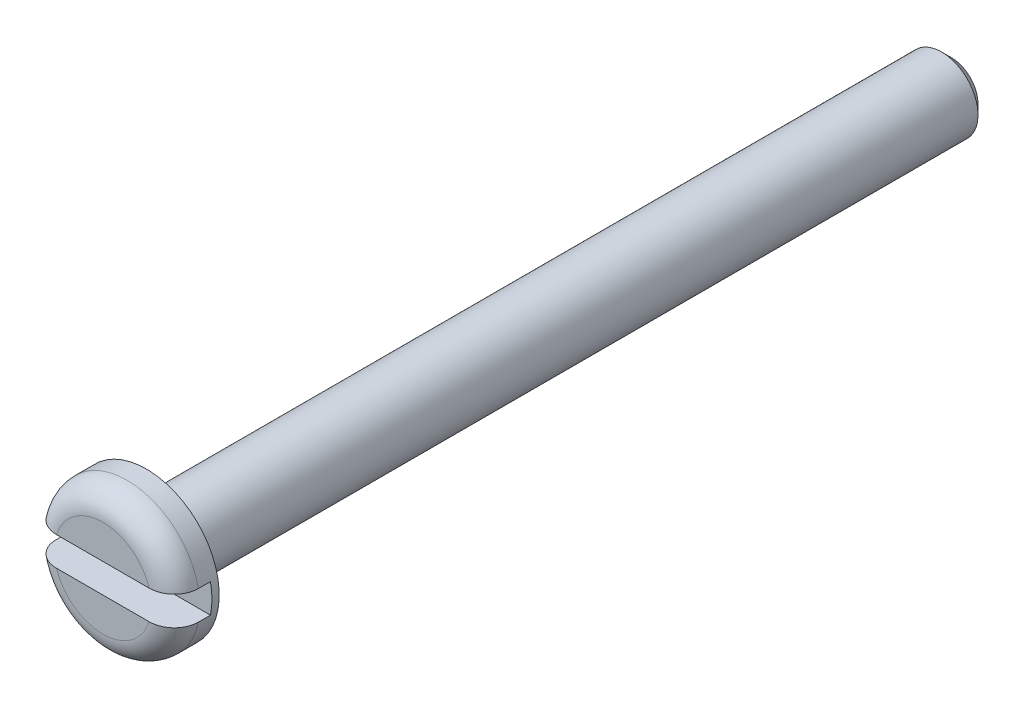
from build123d import *

# Parameters (mm, degrees)
SKETCH_2_W               = 1.5
SKETCH_2_H               = 1.2
CUT_EXTRUDE_1_DEPTH      = 4
CUT_EXTRUDE_1_DEPTH_BACK = 4
CHAMFER_1_SIZE           = 0.4
FILLET_1_R               = 1
FILLET_2_R               = 0.4


with BuildPart() as part:
    # Эскиз1 → Повернуть1 (revolve)
    with BuildSketch(Plane(origin=(0, 0, 0), x_dir=(1, 0, 0), z_dir=(0, 1, 0))):
        Polygon((0, 0), (-3, 0), (-3, 1.8), (-1.5, 1.8), (-1.5, 35), (0, 35), align=None)
    revolve(axis=Axis((0, 0, -35), (0, 0, 1)))

    # Эскиз2 → Вырез-Вытянуть1 (cut, two sides)
    with BuildSketch(Plane(origin=(0, 0, 0), x_dir=(0, 0, -1), z_dir=(1, 0, 0))) as cut_extrude_1_sk:
        with Locations((0.75, 0)):
            Rectangle(SKETCH_2_W, SKETCH_2_H)
    extrude(amount=CUT_EXTRUDE_1_DEPTH, mode=Mode.SUBTRACT)
    extrude(cut_extrude_1_sk.sketch, amount=-CUT_EXTRUDE_1_DEPTH_BACK, mode=Mode.SUBTRACT)

    # Фаска1
    chamfer_1_edges = [part.edges().sort_by_distance(p)[0] for p in [
        (1.5, 0, -35),
    ]]
    chamfer(chamfer_1_edges, length=CHAMFER_1_SIZE)

    # Скругление1
    fillet_1_edges = [part.edges().sort_by_distance(p)[0] for p in [
        (0, 3, 0),
        (0, -3, 0),
    ]]
    fillet(fillet_1_edges, radius=FILLET_1_R)

    # Скругление2
    fillet_2_edges = [part.edges().sort_by_distance(p)[0] for p in [
        (1.5, 0, -1.8),
    ]]
    fillet(fillet_2_edges, radius=FILLET_2_R)


solid = part.part
